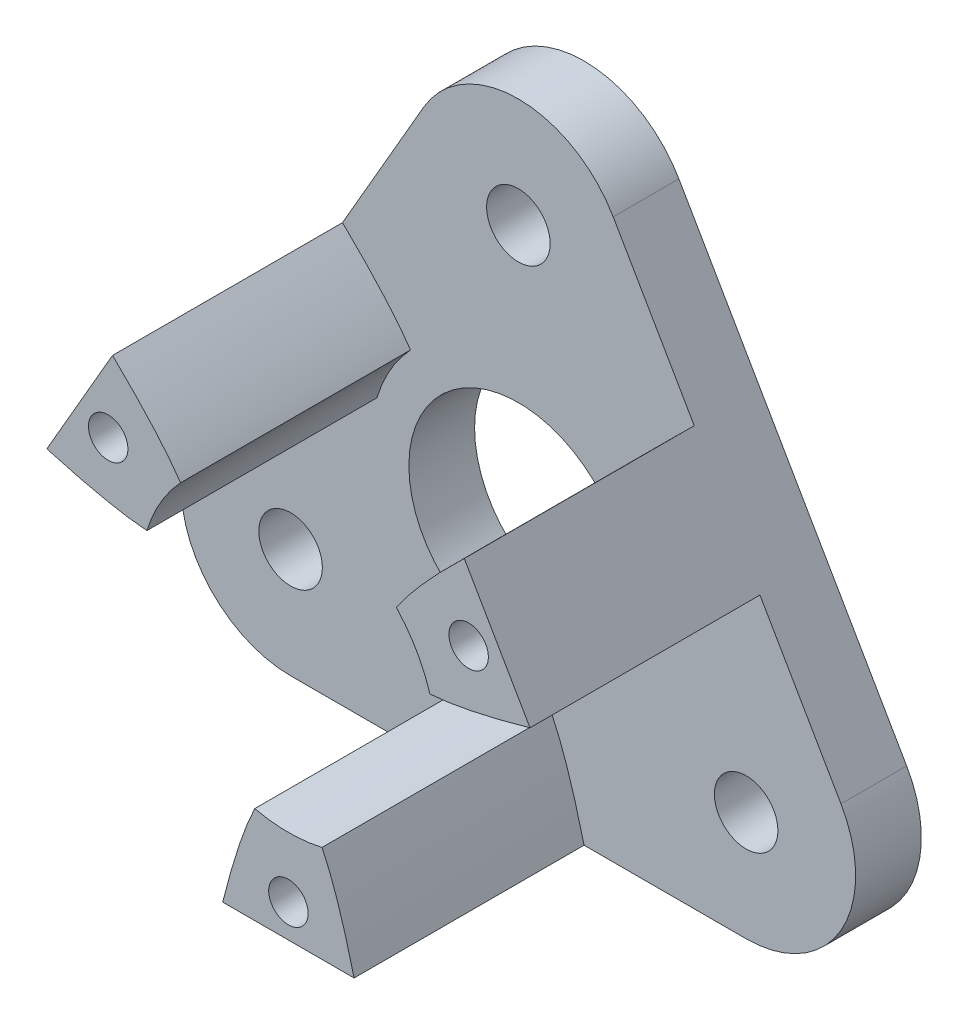
from build123d import *

# Parameters (mm, degrees)
SKETCH1_R           = 1.45
SKETCH1_R_2         = 5
BOSS_EXTRUDE1_DEPTH = 3
BOSS_EXTRUDE2_DEPTH = 10.5
SKETCH3_R           = 6.75
CUT_EXTRUDE1_DEPTH  = 11.5000001
SKETCH4_R           = 0.9
CUT_EXTRUDE2_DEPTH  = 14.5


with BuildPart() as part:
    # Sketch1 → Boss-Extrude1 (new body)
    with BuildSketch(Plane.XY):
        with BuildLine():
            Line((-14.730127019, -3.5044428), (-4.330127019, 14.508885599))
            ThreePointArc((-4.330127019, 14.508885599), (0, 17.008885599), (4.330127019, 14.508885599))
            Line((4.330127019, 14.508885599), (14.730127019, -3.5044428))
            ThreePointArc((14.730127019, -3.5044428), (14.730127019, -8.5044428), (10.4, -11.0044428))
            Line((10.4, -11.0044428), (-10.4, -11.0044428))
            ThreePointArc((-10.4, -11.0044428), (-14.730127019, -8.5044428), (-14.730127019, -3.5044428))
        make_face()
        with Locations((0, 12.008885599)):
            Circle(SKETCH1_R, mode=Mode.SUBTRACT)
        with Locations((-10.4, -6.0044428)):
            Circle(SKETCH1_R, mode=Mode.SUBTRACT)
        with Locations((10.4, -6.0044428)):
            Circle(SKETCH1_R, mode=Mode.SUBTRACT)
        Circle(SKETCH1_R_2, mode=Mode.SUBTRACT)
    extrude(amount=BOSS_EXTRUDE1_DEPTH)

    # Sketch2 → Boss-Extrude2 (add)
    with BuildSketch(Plane.XY.offset(3)):
        with BuildLine():
            Line((8.030127019, 8.100297611), (11.030127019, 2.904145188))
            add(Edge.make_bspline(
                [(8.030127019, 8.100297611), (-0.869872981, -0.5022214), (11.030127019, 2.904145188)],
                knots=[0, 0, 0, 1, 1, 1], degree=2))
        make_face()
        with BuildLine():
            Line((3, -11.0044428), (-3, -11.0044428))
            add(Edge.make_bspline(
                [(3, -11.0044428), (0, 1.0044428), (-3, -11.0044428)],
                knots=[0, 0, 0, 1, 1, 1], degree=2))
        make_face()
        with BuildLine():
            Line((-11.030127019, 2.904145188), (-8.030127019, 8.100297611))
            add(Edge.make_bspline(
                [(-11.030127019, 2.904145188), (0.869872981, -0.5022214), (-8.030127019, 8.100297611)],
                knots=[0, 0, 0, 1, 1, 1], degree=2))
        make_face()
    extrude(amount=BOSS_EXTRUDE2_DEPTH)

    # Sketch3 → Cut-Extrude1 (cut, through all)
    with BuildSketch(Plane.XY.offset(3)):
        Circle(SKETCH3_R)
    extrude(amount=CUT_EXTRUDE1_DEPTH, mode=Mode.SUBTRACT)

    # Sketch4 → Cut-Extrude2 (cut, through all)
    with BuildSketch(Plane.XY.offset(13.5)):
        with Locations((8.229165125, 4.7511107)):
            Circle(SKETCH4_R)
        with Locations((0, -9.5022214)):
            Circle(SKETCH4_R)
        with Locations((-8.229165125, 4.7511107)):
            Circle(SKETCH4_R)
    extrude(amount=-CUT_EXTRUDE2_DEPTH, mode=Mode.SUBTRACT)


solid = part.part
